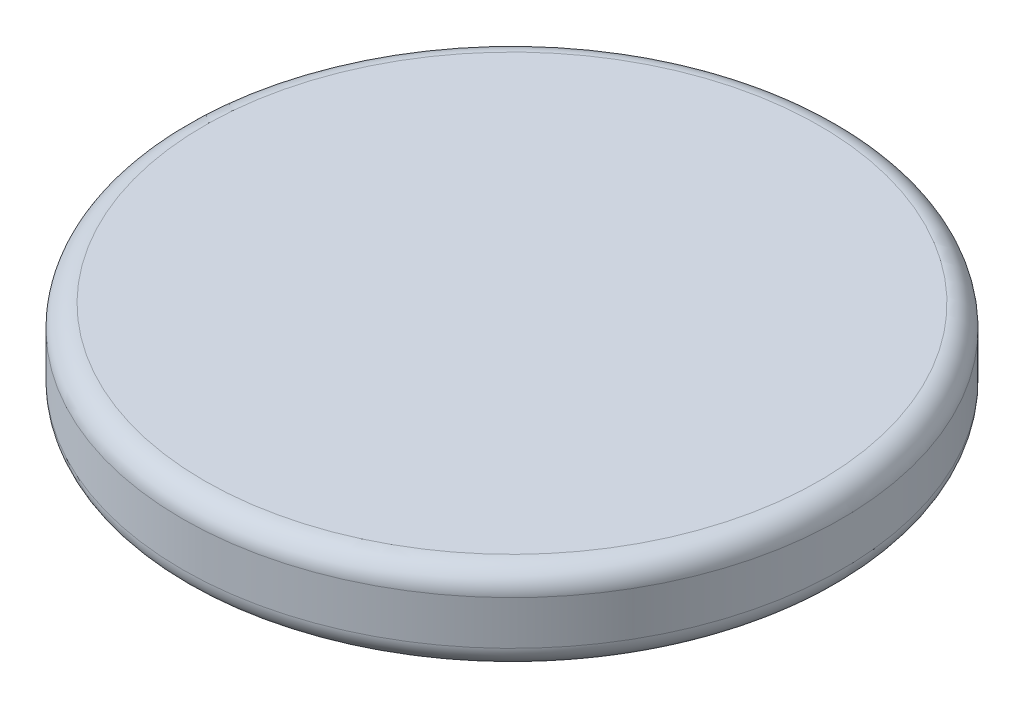
from build123d import *

# Parameters (mm, degrees)
SKETCH1_R           = 7.5
BOSS_EXTRUDE1_DEPTH = 2
FILLET1_R           = 0.5


with BuildPart() as part:
    # Sketch1 → Boss-Extrude1 (new body)
    with BuildSketch(Plane(origin=(0, 0, 0), x_dir=(1, 0, 0), z_dir=(0, 1, 0))):
        Circle(SKETCH1_R)
    extrude(amount=BOSS_EXTRUDE1_DEPTH)

    # Fillet1
    fillet1_edges = [part.edges().sort_by_distance(p)[0] for p in [
        (-7.5, 0, 0),
        (-7.5, 2, 0),
    ]]
    fillet(fillet1_edges, radius=FILLET1_R)


solid = part.part
